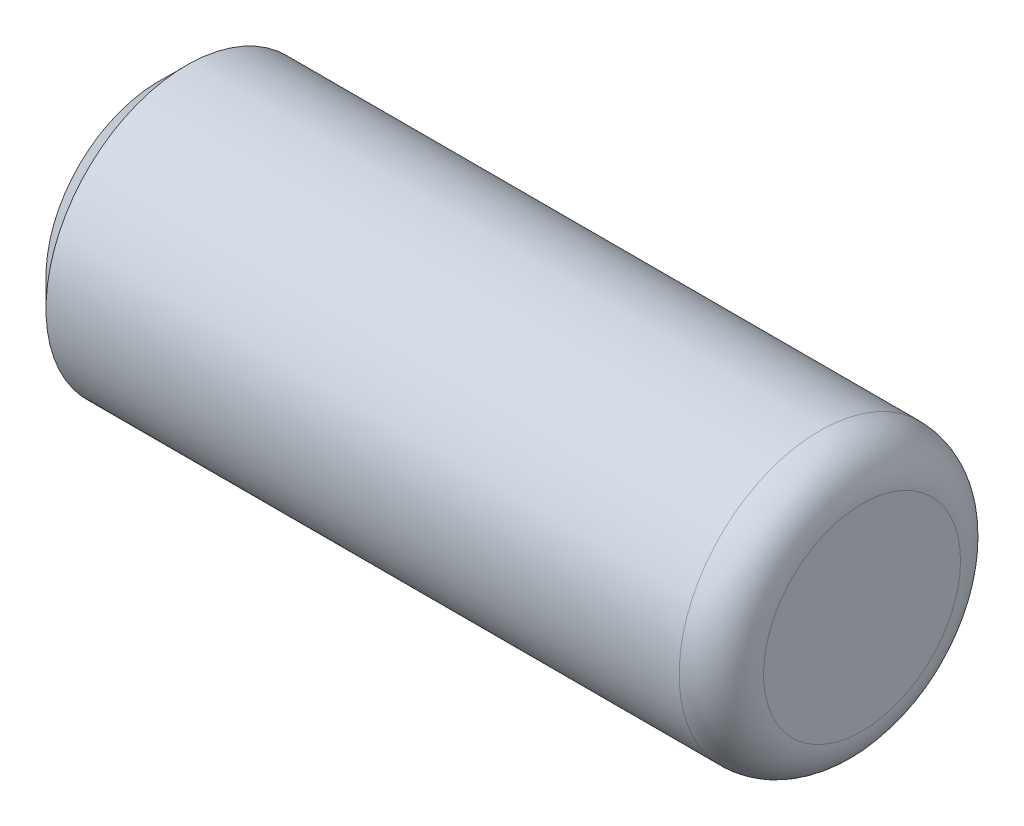
from build123d import *

# Parameters (mm, degrees)
SKETCH1_R           = 1
BOSS_EXTRUDE1_DEPTH = 2.5
FILLET1_R           = 0.3
CHAMFER1_SIZE       = 0.2


with BuildPart() as part:
    # Sketch1 → Boss-Extrude1 (new body, symmetric)
    with BuildSketch(Plane(origin=(0, 0, 0), x_dir=(0, -1, 0), z_dir=(1, 0, 0))):
        Circle(SKETCH1_R)
    extrude(amount=BOSS_EXTRUDE1_DEPTH, both=True)

    # Fillet1
    fillet1_edges = [part.edges().sort_by_distance(p)[0] for p in [
        (2.5, 1, 0),
    ]]
    fillet(fillet1_edges, radius=FILLET1_R)

    # Chamfer1
    chamfer1_edges = [part.edges().sort_by_distance(p)[0] for p in [
        (-2.5, 1, 0),
    ]]
    chamfer(chamfer1_edges, length=CHAMFER1_SIZE)


solid = part.part
